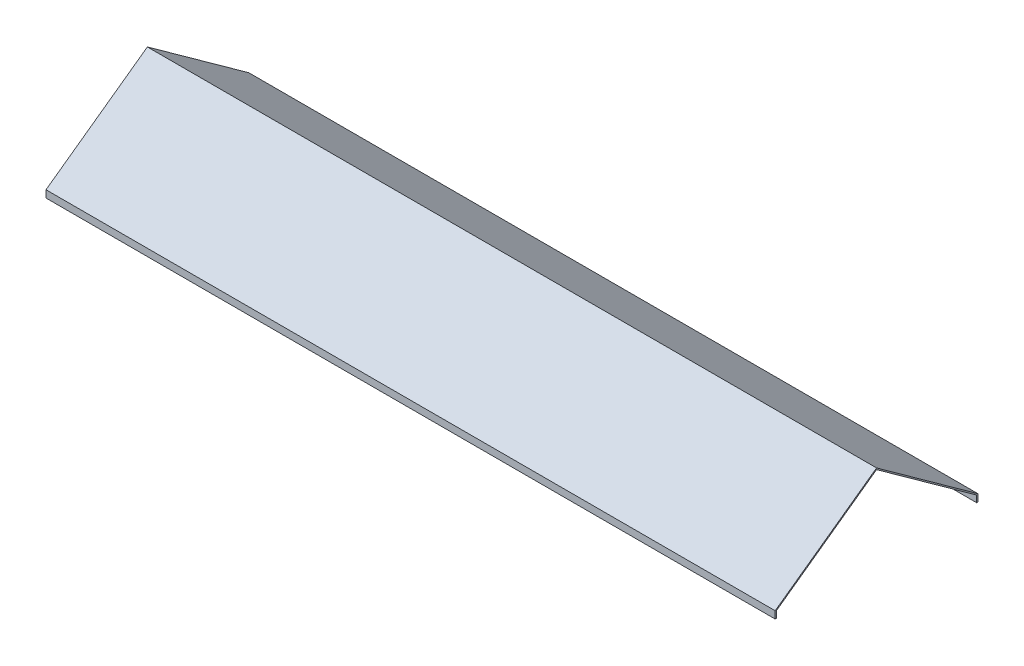
from build123d import *

# Parameters (mm, degrees)
BOSS_EXTRUDE1_DEPTH = 910


with BuildPart() as part:
    # Sketch1 → Boss-Extrude1 (new body)
    with BuildSketch(Plane(origin=(0, 0, 0), x_dir=(0, 0, -1), z_dir=(1, 0, 0))):
        Polygon((-125, 0), (0, 90), (125, 0), (125, -8.303306049), (126.599523146, -8.303306049), (126.599523146, 0.696693951), (0, 91.848350616), (-126.5, 0.768350616), (-126.5, -8.231649384), (-125, -8.231649384), align=None)
    extrude(amount=BOSS_EXTRUDE1_DEPTH)


solid = part.part
